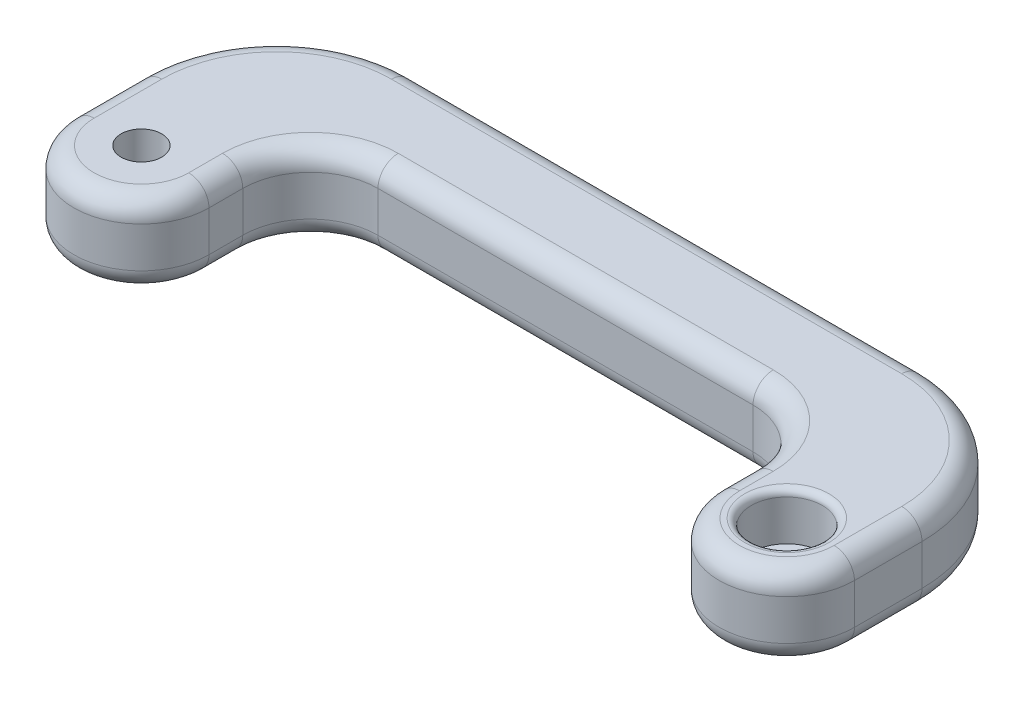
from build123d import *

# Parameters (mm, degrees)
SKETCH7_R           = 5
BOSS_EXTRUDE5_DEPTH = 12
FILLET2_R           = 20
FILLET3_R           = 10
FILLET5_R           = 3
SKETCH11_R          = 5.25
CUT_EXTRUDE1_DEPTH  = 25
FILLET6_R           = 1
SKETCH13_R          = 6.25
SKETCH13_R_2        = 3
BOSS_EXTRUDE7_DEPTH = 5
SKETCH14_R          = 6.25
SKETCH14_R_2        = 3
BOSS_EXTRUDE8_DEPTH = 5


with BuildPart() as part:
    # Sketch7 → Boss-Extrude5 (new body)
    with BuildSketch(Plane(origin=(0, 0, 0), x_dir=(1, 0, 0), z_dir=(0, 1, 0))):
        with BuildLine():
            Line((-105.5, 30), (-105.5, 0))
            ThreePointArc((-105.5, 0), (-95.5, -10), (-85.5, 0))
            Line((-85.5, 0), (-85.5, 15))
            Line((-85.5, 15), (-10, 15))
            Line((-10, 15), (-10, 0))
            ThreePointArc((-10, 0), (0, -10), (10, 0))
            Line((10, 0), (10, 30))
            Line((10, 30), (-10, 30))
            Line((-10, 30), (-85.5, 30))
            Line((-85.5, 30), (-105.5, 30))
        make_face()
        with Locations((-95.5, 0)):
            Circle(SKETCH7_R, mode=Mode.SUBTRACT)
    extrude(amount=BOSS_EXTRUDE5_DEPTH)

    # Fillet2
    fillet2_edges = [part.edges().sort_by_distance(p)[0] for p in [
        (-105.5, 6, -30),
        (10, 6, -30),
    ]]
    fillet(fillet2_edges, radius=FILLET2_R)

    # Fillet3
    fillet3_edges = [part.edges().sort_by_distance(p)[0] for p in [
        (-10, 6, -15),
        (-85.5, 6, -15),
    ]]
    fillet(fillet3_edges, radius=FILLET3_R)

    # Fillet5
    fillet5_edges = [part.edges().sort_by_distance(p)[0] for p in [
        (10, 0, -5),
        (-105.5, 12, -5),
        (0, 0, 10),
        (-10, 0, -2.5),
        (-85.5, 0, -2.5),
        (-95.5, 0, 10),
        (-105.5, 0, -5),
        (-95.5, 12, 10),
        (-85.5, 12, -2.5),
        (-47.75, 0, -30),
        (-47.75, 12, -30),
        (-10, 12, -2.5),
        (-99.642135624, 0, -24.142135624),
        (4.142135624, 0, -24.142135624),
        (-99.642135624, 12, -24.142135624),
        (4.142135624, 12, -24.142135624),
        (0, 12, 10),
        (10, 12, -5),
        (-47.75, 0, -15),
        (-47.75, 12, -15),
        (-12.928932188, 0, -12.071067812),
        (-12.928932188, 12, -12.071067812),
        (-82.571067812, 0, -12.071067812),
        (-82.571067812, 12, -12.071067812),
    ]]
    fillet(fillet5_edges, radius=FILLET5_R)

    # Sketch11 → Cut-Extrude1 (cut)
    with BuildSketch(Plane.XZ):
        with Locations((-95.5, 0)):
            Circle(SKETCH11_R)
        Circle(SKETCH11_R)
    extrude(amount=-CUT_EXTRUDE1_DEPTH, mode=Mode.SUBTRACT)

    # Fillet6
    fillet6_edges = [part.edges().sort_by_distance(p)[0] for p in [
        (-100.75, 12, 0),
        (-100.75, 0, 0),
        (-5.25, 12, 0),
        (-5.25, 0, 0),
    ]]
    fillet(fillet6_edges, radius=FILLET6_R)

    # Sketch13 → Boss-Extrude7 (add)
    with BuildSketch(Plane.XZ):
        Circle(SKETCH13_R)
        Circle(SKETCH13_R_2, mode=Mode.SUBTRACT)
    extrude(amount=-BOSS_EXTRUDE7_DEPTH)

    # Sketch14 → Boss-Extrude8 (add)
    with BuildSketch(Plane(origin=(0, 12, 0), x_dir=(1, 0, 0), z_dir=(0, 1, 0))):
        with Locations((-95.5, 0)):
            Circle(SKETCH14_R)
        with Locations((-95.5, 0)):
            Circle(SKETCH14_R_2, mode=Mode.SUBTRACT)
    extrude(amount=-BOSS_EXTRUDE8_DEPTH)


solid = part.part
